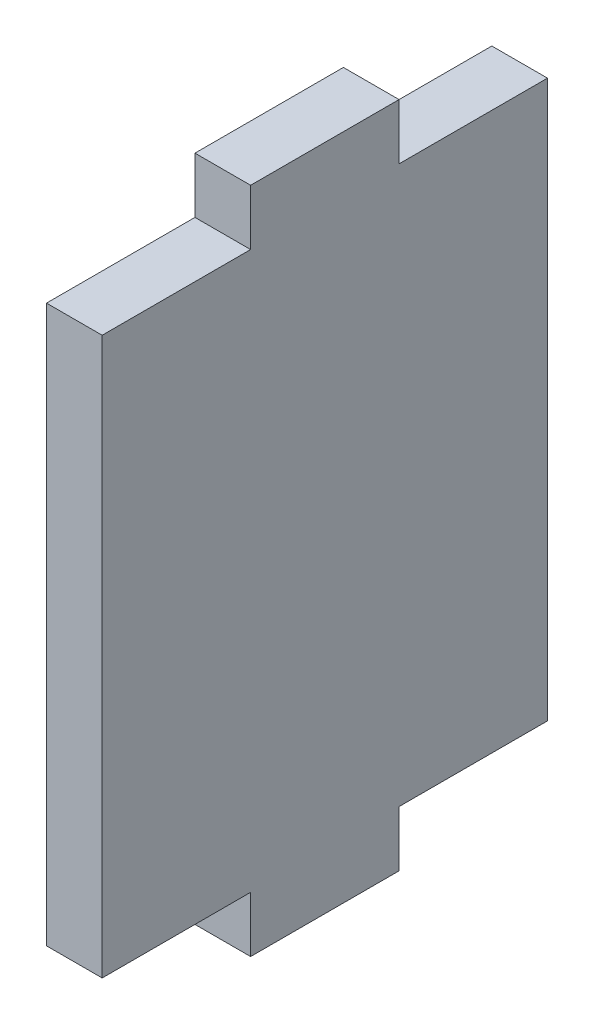
from build123d import *

# Parameters (mm, degrees)
BOSS_EXTRUDE1_DEPTH = 3


with BuildPart() as part:
    # Sketch1 → Boss-Extrude1 (new body)
    with BuildSketch(Plane(origin=(0, 0, 0), x_dir=(0, 0, -1), z_dir=(1, 0, 0))):
        Polygon((-4, 18), (-4, 15), (-12, 15), (-12, -15), (-4, -15), (-4, -18), (4, -18), (4, -15), (12, -15), (12, 15), (4, 15), (4, 18), align=None)
    extrude(amount=BOSS_EXTRUDE1_DEPTH)


solid = part.part
